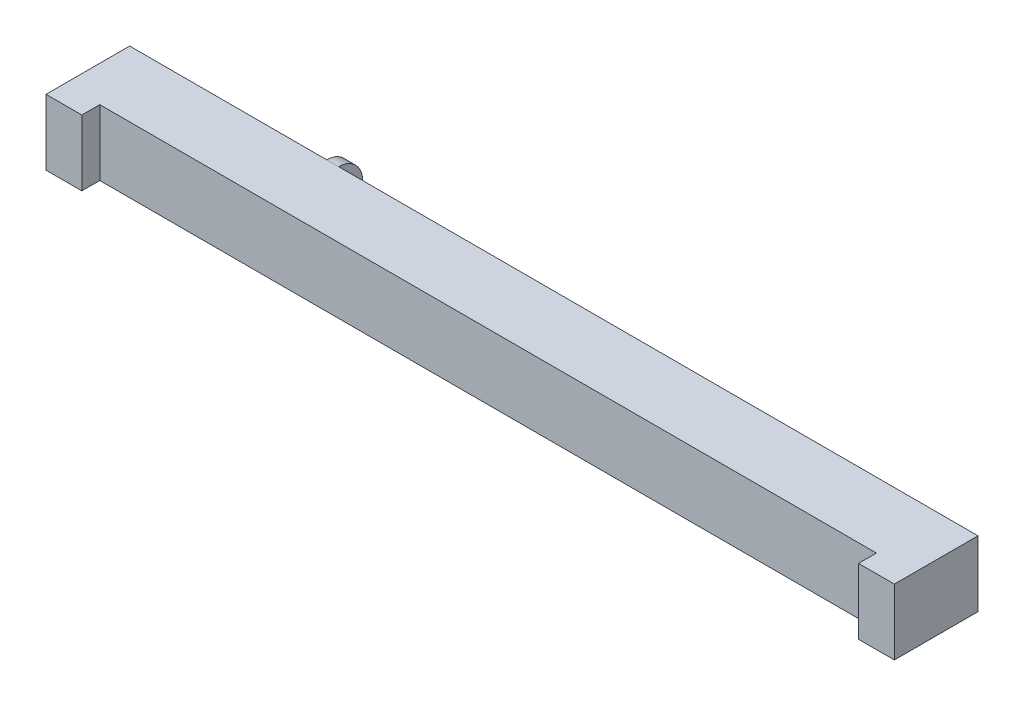
from build123d import *

# Parameters (mm, degrees)
CROQUIS1_W            = 71
CROQUIS1_H            = 7
EXTRUIR1_DEPTH        = 5.5
CROQUIS2_W            = 65
CROQUIS2_H            = 2.766320183
CORTAR_EXTRUIR1_DEPTH = 7.5
CROQUIS3_W            = 63
CROQUIS3_H            = 2
EXTRUIR2_DEPTH        = 5.5
CROQUIS4_W            = 49.5
CROQUIS4_H            = 2
CROQUIS4_W_2          = 12.5
CORTAR_EXTRUIR2_DEPTH = 2.9
REDONDEO1_R           = 2
CROQUIS5_W            = 15.670728733
CROQUIS5_H            = 1.800640157
CROQUIS5_W_2          = 52.74714617
CORTAR_EXTRUIR3_DEPTH = 2.9


with BuildPart() as part:
    # Croquis1 → Extruir1 (new body)
    with BuildSketch(Plane(origin=(0, 0, 0), x_dir=(1, 0, 0), z_dir=(0, 1, 0))):
        Rectangle(CROQUIS1_W, CROQUIS1_H)
    extrude(amount=EXTRUIR1_DEPTH)

    # Croquis2 → Cortar-Extruir1 (cut)
    with BuildSketch(Plane(origin=(0, 5.5, 0), x_dir=(-1, 0, 0), z_dir=(0, 1, 0))):
        with Locations((0, 3.383160092)):
            Rectangle(CROQUIS2_W, CROQUIS2_H)
    extrude(amount=-CORTAR_EXTRUIR1_DEPTH, mode=Mode.SUBTRACT)

    # Croquis3 → Extruir2 (add)
    with BuildSketch(Plane(origin=(0, 5.5, 0), x_dir=(-1, 0, 0), z_dir=(0, 1, 0))):
        with Locations((0, -4.5)):
            Rectangle(CROQUIS3_W, CROQUIS3_H)
    extrude(amount=-EXTRUIR2_DEPTH)

    # Croquis4 → Cortar-Extruir2 (cut)
    with BuildSketch(Plane(origin=(0, 5.5, 0), x_dir=(-1, 0, 0), z_dir=(0, 1, 0))):
        with Locations((-6.75, -4.5)):
            Rectangle(CROQUIS4_W, CROQUIS4_H)
        with Locations((25.25, -4.5)):
            Rectangle(CROQUIS4_W_2, CROQUIS4_H)
    extrude(amount=-CORTAR_EXTRUIR2_DEPTH, mode=Mode.SUBTRACT)

    # Redondeo1
    redondeo1_edges = [part.edges().sort_by_distance(p)[0] for p in [
        (-18.5, 5.5, -5.5),
    ]]
    fillet(redondeo1_edges, radius=REDONDEO1_R)

    # Croquis5 → Cortar-Extruir3 (cut)
    with BuildSketch(Plane(origin=(0, 0, -3.5), x_dir=(-1, 0, 0), z_dir=(0, 0, -1))):
        with Locations((26.835364367, 4.033789802)):
            Rectangle(CROQUIS5_W, CROQUIS5_H)
        with Locations((-8.373573085, 4.033789802)):
            Rectangle(CROQUIS5_W_2, CROQUIS5_H)
    extrude(amount=-CORTAR_EXTRUIR3_DEPTH, mode=Mode.SUBTRACT)


solid = part.part
